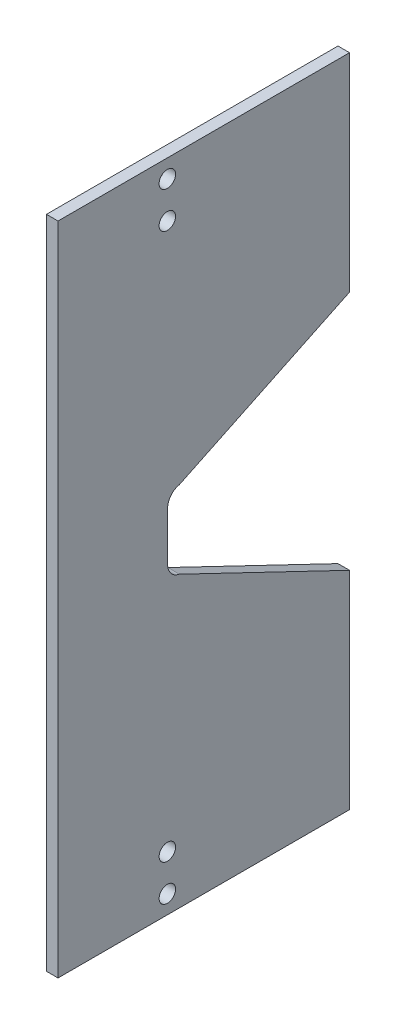
from build123d import *

# Parameters (mm, degrees)
SKETCH_1_R          = 1.1303
EXTRUDE_1_DEPTH     = 1.588
FILLET_1_R          = 2
FILLET_2_R          = 2
FILLET_3_R          = 2
FILLET_4_R          = 2
SKETCH_2_W          = 12
SKETCH_2_H          = 89.95
EXTRUDE_2_DEPTH     = 1.588
CUT_EXTRUDE_1_DEPTH = 10


with BuildPart() as part:
    # 草图1 → 凸台-拉伸1 (new body)
    with BuildSketch(Plane(origin=(-0.79375, 0, 0), x_dir=(0, -1, 0), z_dir=(-1, 0, 0))):
        with BuildLine():
            Line((38.795, 5), (12.795, 5))
            ThreePointArc((12.795, 5), (11.380786438, 4.414213562), (10.795, 3))
            Line((10.795, 3), (10.795, -13))
            ThreePointArc((10.795, -13), (11.380786438, -14.414213562), (12.795, -15))
            Line((12.795, -15), (47.795, -15))
            Line((47.795, -15), (50.77, -0.039144756))
            Line((50.77, -0.039144756), (55.77, -0.039144756))
            Line((55.77, -0.039144756), (60.77, -0.039144756))
            Line((60.77, -0.039144756), (63.745, -15))
            Line((63.745, -15), (98.745, -15))
            ThreePointArc((98.745, -15), (100.159213562, -14.414213562), (100.745, -13))
            Line((100.745, -13), (100.745, 3))
            ThreePointArc((100.745, 3), (100.159213562, 4.414213562), (98.745, 5))
            Line((98.745, 5), (72.745, 5))
            Line((72.745, 5), (38.795, 5))
        make_face()
        with Locations((18.295, 0)):
            Circle(SKETCH_1_R, mode=Mode.SUBTRACT)
        with Locations((13.295, 0)):
            Circle(SKETCH_1_R, mode=Mode.SUBTRACT)
        with Locations((98.245, 0)):
            Circle(SKETCH_1_R, mode=Mode.SUBTRACT)
        with Locations((93.245, 0)):
            Circle(SKETCH_1_R, mode=Mode.SUBTRACT)
    extrude(amount=-EXTRUDE_1_DEPTH)

    # 圆角1
    fillet_1_edges = [part.edges().sort_by_distance(p)[0] for p in [
        (0.00025, -50.77, -0.039144756),
    ]]
    fillet(fillet_1_edges, radius=FILLET_1_R)

    # 圆角2
    fillet_2_edges = [part.edges().sort_by_distance(p)[0] for p in [
        (0.00025, -47.795, -15),
    ]]
    fillet(fillet_2_edges, radius=FILLET_2_R)

    # 圆角3
    fillet_3_edges = [part.edges().sort_by_distance(p)[0] for p in [
        (0.00025, -60.77, -0.039144756),
    ]]
    fillet(fillet_3_edges, radius=FILLET_3_R)

    # 圆角4
    fillet_4_edges = [part.edges().sort_by_distance(p)[0] for p in [
        (0.00025, -63.745, -15),
    ]]
    fillet(fillet_4_edges, radius=FILLET_4_R)

    # 草图2 → 凸台-拉伸2 (add)
    with BuildSketch(Plane.ZY.offset(0.79375)):
        with Locations((9, -55.77)):
            Rectangle(SKETCH_2_W, SKETCH_2_H)
        Polygon((-25, -10.795), (-25, -45.806477318), (-13.39006724, -48.115138781), (-13, -10.795), align=None)
        Polygon((-13.39006724, -63.424861219), (-25, -65.733522682), (-25, -100.745), (-13, -100.745), align=None)
    extrude(amount=-EXTRUDE_2_DEPTH)

    # 草图5 → 切除-拉伸1 (cut)
    with BuildSketch(Plane(origin=(0.79425, 0, 0), x_dir=(0, 0, -1), z_dir=(1, 0, 0))):
        Polygon((1.649077515, -50.449861219), (25, -45.806477318), (25, -39.241825321), align=None)
        Polygon((25, -72.298174679), (25, -65.733522682), (1.649077515, -61.090138781), align=None)
    extrude(amount=-CUT_EXTRUDE_1_DEPTH, mode=Mode.SUBTRACT)


solid = part.part
